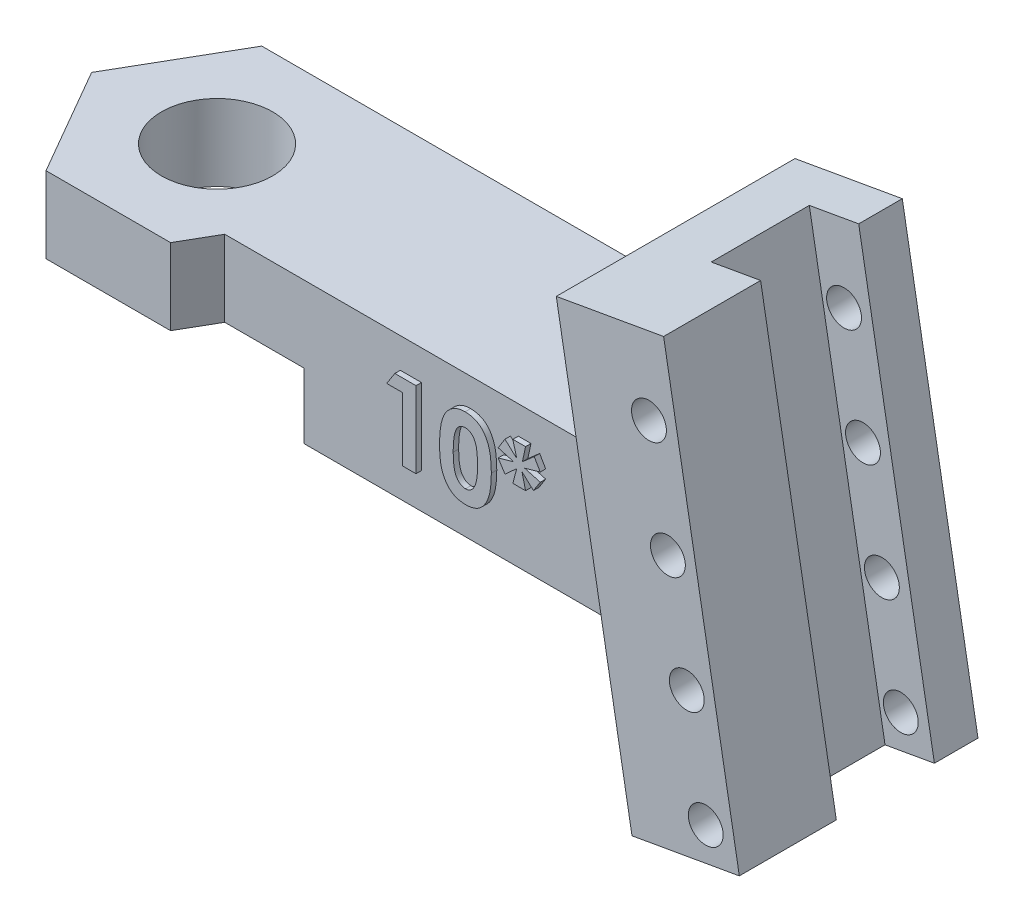
from build123d import *

# Parameters (mm, degrees)
SKETCH1_W                = 25
SKETCH1_H                = 6.75
BOSS_EXTRUDE1_DEPTH      = 6.5
BOSS_EXTRUDE4_DEPTH      = 6.5
BOSS_EXTRUDE3_DEPTH      = 6
BOSS_EXTRUDE3_DEPTH_BACK = 4.95
SKETCH4_W                = 2.3
SKETCH4_H                = 4.5
CUT_EXTRUDE1_DEPTH       = 23
SKETCH6_R                = 2.55
CUT_EXTRUDE2_DEPTH       = 10
BOSS_EXTRUDE5_DEPTH      = 1.575
CUT_EXTRUDE3_DEPTH       = 3
SKETCH9_R                = 0.8
CUT_EXTRUDE4_DEPTH       = 10.95
BOSS_EXTRUDE6_DEPTH      = 0.25


with BuildPart() as part:
    # Sketch1 → Boss-Extrude1 (new body)
    with BuildSketch(Plane(origin=(0, 0, 0), x_dir=(1, 0, 0), z_dir=(0, 1, 0))):
        with Locations((12.5, -3.375)):
            Rectangle(SKETCH1_W, SKETCH1_H)
    extrude(amount=BOSS_EXTRUDE1_DEPTH)

    # Sketch5 → Boss-Extrude4 (add)
    with BuildSketch(Plane(origin=(0, 6.5, 0), x_dir=(1, 0, 0), z_dir=(0, 1, 0))):
        Polygon((-5.715767665, -3.375), (-2.857883832, -8.325), (2.857883832, -8.325), (5.715767665, -3.375), (2.857883832, 1.575), (-2.857883832, 1.575), align=None)
    extrude(amount=-BOSS_EXTRUDE4_DEPTH)

    # Sketch3 → Boss-Extrude3 (add, two sides)
    with BuildSketch(Plane.XY.offset(3.375)) as boss_extrude3_sk:
        Polygon((21.602997682, 14.262034616), (26.527036447, 15.130275504), (30, -4.565879556), (25.075961235, -5.434120444), align=None)
    extrude(amount=BOSS_EXTRUDE3_DEPTH)
    extrude(boss_extrude3_sk.sketch, amount=-BOSS_EXTRUDE3_DEPTH_BACK)

    # Sketch4 → Cut-Extrude1 (cut)
    with BuildSketch(Plane(origin=(-1.787541475, 10.137651469, 0), x_dir=(0.984807753, 0.173648178, 0), z_dir=(-0.173648178, 0.984807753, 0))):
        with Locations((27.601375926, -2.675)):
            Rectangle(SKETCH4_W, SKETCH4_H)
    extrude(amount=-CUT_EXTRUDE1_DEPTH, mode=Mode.SUBTRACT)

    # Sketch6 → Cut-Extrude2 (cut)
    with BuildSketch(Plane(origin=(0, 6.5, 0), x_dir=(1, 0, 0), z_dir=(0, 1, 0))):
        with Locations((0, -3.335615973)):
            Circle(SKETCH6_R)
    extrude(amount=-CUT_EXTRUDE2_DEPTH, mode=Mode.SUBTRACT)

    # Sketch7 → Boss-Extrude5 (add)
    with BuildSketch(Plane(origin=(0, 0, -1.575), x_dir=(-1, 0, 0), z_dir=(0, 0, -1))):
        Polygon((-2.857883832, 0), (-24.117779184, 0), (-25.075961235, -5.434120444), (-30, -4.565879556), (-26.527036447, 15.130275504), (-21.602997682, 14.262034616), (-22.97165381, 6.5), (-2.857883832, 6.5), align=None)
    extrude(amount=-BOSS_EXTRUDE5_DEPTH)

    # Sketch8 → Cut-Extrude3 (cut)
    with BuildSketch(Plane(origin=(0, 0, 0), x_dir=(-1, 0, 0), z_dir=(0, -1, 0))):
        Polygon((-4.67653718, -11.475), (4.67653718, -11.475), (9.353074361, -3.375), (4.67653718, 4.725), (-4.67653718, 4.725), (-9.353074361, -3.375), align=None)
    extrude(amount=-CUT_EXTRUDE3_DEPTH, mode=Mode.SUBTRACT)

    # Sketch9 → Cut-Extrude4 (cut)
    with BuildSketch(Plane(origin=(0, 0, -1.575), x_dir=(-1, 0, 0), z_dir=(0, 0, -1))):
        with Locations((-28.459277655, -3.314410557)):
            Circle(SKETCH9_R)
        with Locations((-27.591036766, 1.609628208)):
            Circle(SKETCH9_R)
        with Locations((-26.722795878, 6.533666973)):
            Circle(SKETCH9_R)
        with Locations((-25.85455499, 11.457705738)):
            Circle(SKETCH9_R)
    extrude(amount=-CUT_EXTRUDE4_DEPTH, mode=Mode.SUBTRACT)

    # Sketch10 → Boss-Extrude6 (add)
    with BuildSketch(Plane.XY.offset(6.75)):
        Polygon((11.821517388, 5.121255448), (12.792571074, 5.121255448), (12.792571074, 1.621255448), (12.164365946, 1.621255448), (12.164365946, 4.537922115), (11.446417228, 4.537922115), align=None)
        with BuildLine():
            add(Edge.make_bspline(
                [(15.048079888, 5.210999038), (15.078487624, 5.210547627), (15.138277356, 5.209660031), (15.226336378, 5.20004665), (15.311161562, 5.185523511), (15.393084756, 5.165268798), (15.471516268, 5.138462406), (15.54702694, 5.106375614), (15.618717974, 5.067325404), (15.687503662, 5.023216186), (15.753357507, 4.973278299), (15.814696757, 4.916346529), (15.872641599, 4.853730878), (15.925937739, 4.784484711), (15.975765436, 4.709237895), (16.021960966, 4.627978498), (16.064170689, 4.540308809), (16.102867677, 4.446070622), (16.137470646, 4.343851347), (16.166616684, 4.232478485), (16.191614288, 4.111926601), (16.21271403, 3.981895624), (16.228662025, 3.842212712), (16.239411294, 3.692970662), (16.246787952, 3.534457192), (16.247389983, 3.425718255), (16.247699279, 3.369853205)],
                knots=[0, 0, 0, 0, 9.1189e-05, 0.000179302, 0.000265406, 0.000349239, 0.000432161, 0.00051382, 0.000595069, 0.000676752, 0.000758786, 0.000842642, 0.00092749, 0.00101444, 0.001104474, 0.001198046, 0.001294628, 0.001396185, 0.001503495, 0.001618119, 0.001741326, 0.001872727, 0.002013179, 0.002162939, 0.002321548, 0.002489129, 0.002489129, 0.002489129, 0.002489129], degree=3))
            add(Edge.make_bspline(
                [(16.247699279, 3.369853205), (16.247365014, 3.31328922), (16.246715542, 3.203386413), (16.239717944, 3.043423099), (16.22766775, 2.893097462), (16.212136589, 2.752425056), (16.190863148, 2.621480168), (16.165948991, 2.499923737), (16.136342892, 2.387799826), (16.100600112, 2.285361073), (16.062137358, 2.190957383), (16.019812173, 2.10345863), (15.974362278, 2.022627817), (15.926830158, 1.947245503), (15.874609927, 1.87953392), (15.82024329, 1.817190519), (15.761363027, 1.762590042), (15.700448226, 1.712918623), (15.635267329, 1.66999255), (15.566492532, 1.632450114), (15.492897697, 1.601998739), (15.415824335, 1.57551376), (15.333958715, 1.556500403), (15.248601668, 1.541413929), (15.158789533, 1.533076218), (15.097641814, 1.53204187), (15.066309055, 1.531511859)],
                knots=[0, 0, 0, 0, 0.000169685, 0.000329694, 0.000480207, 0.000622052, 0.000754146, 0.000878038, 0.000994198, 0.001101735, 0.001203292, 0.001299874, 0.001393102, 0.001481398, 0.001566938, 0.001649385, 0.001729242, 0.001807533, 0.001884926, 0.001963041, 0.002042215, 0.002123584, 0.00220725, 0.002294045, 0.002383484, 0.002477476, 0.002477476, 0.002477476, 0.002477476], degree=3))
            add(Edge.make_bspline(
                [(15.066309055, 1.531511859), (15.034977142, 1.532052093), (14.973598385, 1.533110405), (14.883543389, 1.541351934), (14.797733993, 1.556561518), (14.715220684, 1.575659731), (14.63657774, 1.601940139), (14.561428072, 1.633302597), (14.490349515, 1.670610787), (14.423145264, 1.713636874), (14.360044773, 1.762975953), (14.300067462, 1.818100286), (14.243346003, 1.878870149), (14.19074327, 1.945966213), (14.141397784, 2.018492887), (14.095824138, 2.097278389), (14.054049723, 2.18220801), (14.014767826, 2.273400132), (13.980636829, 2.372818019), (13.950261828, 2.481349457), (13.925379425, 2.599899148), (13.905367332, 2.728429006), (13.889389688, 2.866666733), (13.877504158, 3.014679055), (13.870467691, 3.17253491), (13.869825031, 3.281037103), (13.869494151, 3.33690048)],
                knots=[0, 0, 0, 0, 9.3992e-05, 0.000184129, 0.000270924, 0.000355272, 0.000437971, 0.000519356, 0.000599327, 0.000678482, 0.000758422, 0.000839307, 0.000922649, 0.001007511, 0.001094825, 0.001185617, 0.00128031, 0.001378632, 0.00148329, 0.001595393, 0.001716541, 0.001846447, 0.001985506, 0.002133922, 0.00229183, 0.002459412, 0.002459412, 0.002459412, 0.002459412], degree=3))
            add(Edge.make_bspline(
                [(13.869494151, 3.33690048), (13.870093509, 3.414518246), (13.871249978, 3.564282724), (13.885905598, 3.78064885), (13.907416331, 3.980641854), (13.939010504, 4.163927197), (13.978076261, 4.331183713), (14.028101996, 4.481309605), (14.085052658, 4.6163822), (14.133581938, 4.696400019), (14.156954087, 4.734937339)],
                knots=[0, 0, 0, 0, 0.00023281, 0.000449211, 0.000650286, 0.000835979, 0.001006883, 0.001164965, 0.001310334, 0.001445389, 0.001445389, 0.001445389, 0.001445389], degree=3))
            add(Edge.make_bspline(
                [(14.156954087, 4.734937339), (14.184130109, 4.772796391), (14.237264587, 4.846818296), (14.330171707, 4.943995222), (14.42998831, 5.027105688), (14.538764575, 5.094268828), (14.654780157, 5.147233687), (14.77903111, 5.18464217), (14.911058597, 5.206438095), (15.001724074, 5.209456021), (15.048079888, 5.210999038)],
                knots=[0, 0, 0, 0, 0.000139664, 0.000273071, 0.000402072, 0.00052834, 0.000655415, 0.000783615, 0.000916514, 0.00105555, 0.00105555, 0.00105555, 0.00105555], degree=3))
        make_face()
        with BuildLine():
            add(Edge.make_bspline(
                [(15.063504568, 4.58279391), (15.036015723, 4.581490993), (14.982122994, 4.578936585), (14.903922078, 4.557253264), (14.830183496, 4.523762204), (14.774092526, 4.483460951), (14.732108993, 4.444827367), (14.702774798, 4.409865229), (14.674486589, 4.370850003), (14.649501019, 4.326021133), (14.625908119, 4.276989372), (14.602850744, 4.223532146), (14.583949751, 4.16433643), (14.565380027, 4.100410333), (14.549111215, 4.029986471), (14.535481518, 3.952489204), (14.523304581, 3.867414562), (14.514811023, 3.77470682), (14.506892478, 3.674462974), (14.501216089, 3.566459719), (14.498842934, 3.450726192), (14.49808858, 3.371022229), (14.497699279, 3.329889262)],
                knots=[0, 0, 0, 0, 8.233e-05, 0.000161411, 0.000241719, 0.000324202, 0.000367359, 0.000412607, 0.000460858, 0.000511731, 0.000566293, 0.000624109, 0.000686189, 0.000752544, 0.000823804, 0.000902881, 0.00098855, 0.001081546, 0.001182103, 0.001290221, 0.00140594, 0.001529346, 0.001529346, 0.001529346, 0.001529346], degree=3))
            add(Edge.make_bspline(
                [(14.497699279, 3.329889262), (14.498340021, 3.276599515), (14.499568691, 3.174412475), (14.50600389, 3.027463952), (14.518902713, 2.893728963), (14.534946244, 2.772301138), (14.557480038, 2.663967967), (14.583406627, 2.567704519), (14.61542366, 2.484737918), (14.65242551, 2.413868282), (14.693406726, 2.35357963), (14.737893638, 2.302334004), (14.784371628, 2.257957709), (14.834291423, 2.221911392), (14.887533931, 2.194287156), (14.943654674, 2.174417385), (15.002689316, 2.16225427), (15.043115631, 2.160567637), (15.063504568, 2.159716987)],
                knots=[0, 0, 0, 0, 0.00015988, 0.000306582, 0.00044109, 0.000562851, 0.000673817, 0.000772822, 0.000861618, 0.000940022, 0.001012169, 0.001079776, 0.001143265, 0.001204556, 0.001263825, 0.001322589, 0.001382678, 0.00144382, 0.00144382, 0.00144382, 0.00144382], degree=3))
            add(Edge.make_bspline(
                [(15.063504568, 2.159716987), (15.083193821, 2.160299065), (15.121742931, 2.161438701), (15.177956166, 2.173136917), (15.231115396, 2.192155675), (15.281060116, 2.219059043), (15.327968971, 2.253270793), (15.3716127, 2.294941264), (15.411662151, 2.344485814), (15.434995142, 2.381255198), (15.447018189, 2.400201762)],
                knots=[0, 0, 0, 0, 5.8998e-05, 0.000115512, 0.000171399, 0.00022786, 0.000285078, 0.000345085, 0.000408376, 0.000475658, 0.000475658, 0.000475658, 0.000475658], degree=3))
            add(Edge.make_bspline(
                [(15.447018189, 2.400201762), (15.461173303, 2.426091637), (15.490855427, 2.480380606), (15.525203632, 2.571991216), (15.554116037, 2.675312843), (15.579000521, 2.790667033), (15.596019991, 2.918508758), (15.610677137, 3.058027363), (15.617746642, 3.209925406), (15.618896536, 3.315160919), (15.619494151, 3.369853205)],
                knots=[0, 0, 0, 0, 8.843e-05, 0.000185431, 0.00029262, 0.000410194, 0.000539093, 0.000679319, 0.000830958, 0.000995045, 0.000995045, 0.000995045, 0.000995045], degree=3))
            add(Edge.make_bspline(
                [(15.619494151, 3.369853205), (15.619263305, 3.425020246), (15.618818967, 3.531207384), (15.61066664, 3.683651511), (15.599313902, 3.822883921), (15.582708123, 3.948593764), (15.561341771, 4.061086209), (15.535007661, 4.160353902), (15.503961704, 4.246592481), (15.467144899, 4.319715953), (15.426368, 4.381860874), (15.383082077, 4.435176395), (15.3371041, 4.480695842), (15.288510958, 4.518590513), (15.236177946, 4.547544883), (15.181104694, 4.567989064), (15.123178296, 4.580357108), (15.083664292, 4.581970679), (15.063504568, 4.58279391)],
                knots=[0, 0, 0, 0, 0.000165478, 0.000318517, 0.00045785, 0.000584474, 0.000698739, 0.000801125, 0.000892295, 0.000973192, 0.001046115, 0.001114882, 0.001178838, 0.00123984, 0.001299154, 0.001357499, 0.001415527, 0.00147597, 0.00147597, 0.00147597, 0.00147597], degree=3))
        make_face(mode=Mode.SUBTRACT)
        Polygon((17.234878766, 5.210999038), (17.8182121, 5.210999038), (17.672378766, 4.537922115), (18.215748157, 5.013983814), (18.491289023, 4.537922115), (17.773340305, 4.335999038), (18.491289023, 4.134075961), (18.180692068, 3.647497435), (17.6541496, 4.134075961), (17.8182121, 3.460999038), (17.234878766, 3.460999038), (17.412262581, 4.134075961), (16.873801042, 3.647497435), (16.561801843, 4.134075961), (17.279750561, 4.335999038), (16.561801843, 4.537922115), (16.873801042, 5.036419711), (17.412262581, 4.537922115), align=None)
    extrude(amount=BOSS_EXTRUDE6_DEPTH)


solid = part.part
